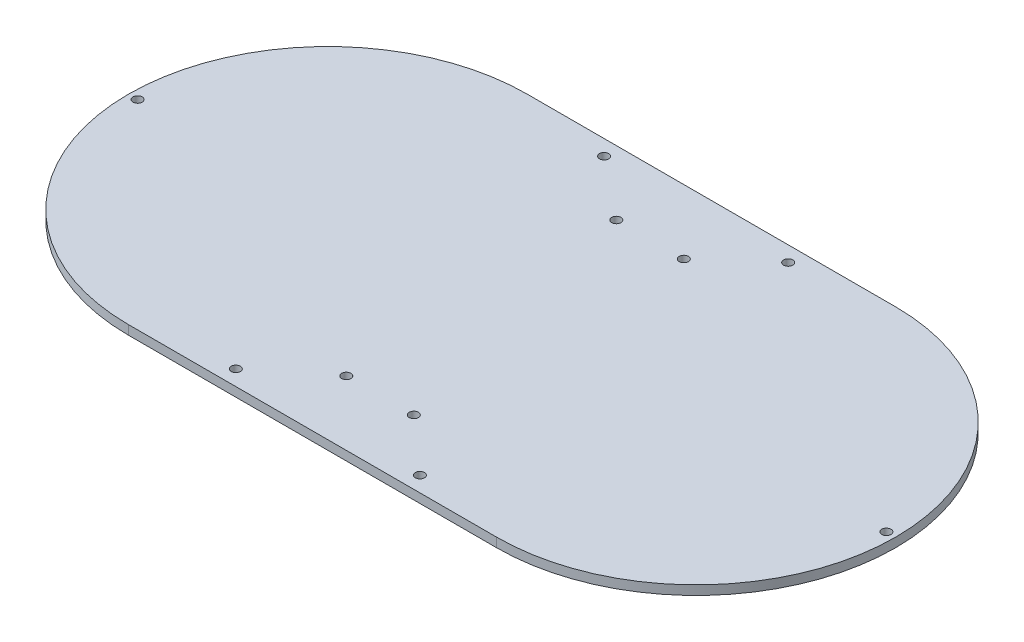
from build123d import *

# Parameters (mm, degrees)
SKETCH_1_R          = 1.5
EXTRUDE_2_DEPTH     = 3
SKETCH_2_R          = 1.5
CUT_EXTRUDE_1_DEPTH = 10


with BuildPart() as part:
    # 草图1 → 凸台-拉伸2 (new body)
    with BuildSketch(Plane(origin=(0, 0, 0), x_dir=(1, 0, 0), z_dir=(0, 1, 0))):
        with BuildLine():
            Line((-60, 65), (60, 65))
            ThreePointArc((60, 65), (125, 0), (60, -65))
            Line((60, -65), (-60, -65))
            ThreePointArc((-60, -65), (-125, 0), (-60, 65))
        make_face()
        with Locations((-122, 0)):
            Circle(SKETCH_1_R, mode=Mode.SUBTRACT)
        with Locations((122, 0)):
            Circle(SKETCH_1_R, mode=Mode.SUBTRACT)
        with Locations((-30, 60)):
            Circle(SKETCH_1_R, mode=Mode.SUBTRACT)
        with Locations((30, 60)):
            Circle(SKETCH_1_R, mode=Mode.SUBTRACT)
        with Locations((30, -60)):
            Circle(SKETCH_1_R, mode=Mode.SUBTRACT)
        with Locations((-30, -60)):
            Circle(SKETCH_1_R, mode=Mode.SUBTRACT)
    extrude(amount=EXTRUDE_2_DEPTH)

    # 草图2 → 切除-拉伸1 (cut)
    with BuildSketch(Plane(origin=(0, 3, 0), x_dir=(1, 0, 0), z_dir=(0, 1, 0))):
        with Locations((-10, 44)):
            Circle(SKETCH_2_R)
        with Locations((12, 44)):
            Circle(SKETCH_2_R)
        with Locations((-10, -44)):
            Circle(SKETCH_2_R)
        with Locations((12, -44)):
            Circle(SKETCH_2_R)
    extrude(amount=-CUT_EXTRUDE_1_DEPTH, mode=Mode.SUBTRACT)


solid = part.part
